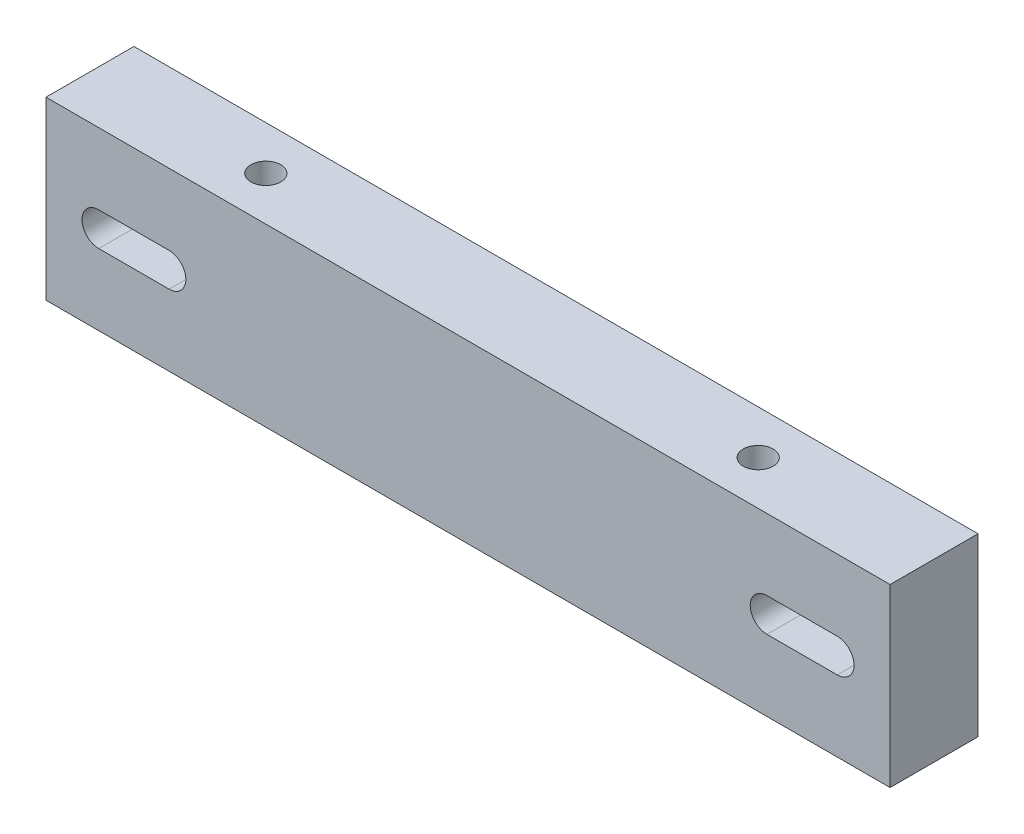
from build123d import *

# Parameters (mm, degrees)
CROQUIS1_W              = 240
CROQUIS1_H              = 25
SALIENTE_EXTRUIR1_DEPTH = 50
CROQUIS2_R              = 4.25
CORTAR_EXTRUIR1_DEPTH   = 25
CORTAR_EXTRUIR3_DEPTH   = 26


with BuildPart() as part:
    # Croquis1 → Saliente-Extruir1 (new body)
    with BuildSketch(Plane(origin=(0, 0, 0), x_dir=(1, 0, 0), z_dir=(0, 1, 0))):
        with Locations((0, 2.5)):
            Rectangle(CROQUIS1_W, CROQUIS1_H)
    extrude(amount=-SALIENTE_EXTRUIR1_DEPTH)

    # Croquis2 → Cortar-Extruir1 (cut)
    with BuildSketch(Plane(origin=(0, 0, 0), x_dir=(1, 0, 0), z_dir=(0, 1, 0))):
        with Locations((-70, 2.5)):
            Circle(CROQUIS2_R)
        with Locations((70, 2.5)):
            Circle(CROQUIS2_R)
    extrude(amount=-CORTAR_EXTRUIR1_DEPTH, mode=Mode.SUBTRACT)

    # Croquis3 → Cortar-Extruir3 (cut, through all)
    with BuildSketch(Plane.XY.offset(10)):
        with BuildLine():
            Line((-105, -20.232520372), (-85, -20.232520372))
            ThreePointArc((-85, -20.232520372), (-80.232520372, -25), (-85, -29.767479628))
            Line((-85, -29.767479628), (-105, -29.767479628))
            ThreePointArc((-105, -29.767479628), (-109.767479628, -25), (-105, -20.232520372))
        make_face()
        with BuildLine():
            Line((85, -20.232520372), (105, -20.232520372))
            ThreePointArc((105, -20.232520372), (109.767479628, -25), (105, -29.767479628))
            Line((105, -29.767479628), (85, -29.767479628))
            ThreePointArc((85, -29.767479628), (80.232520372, -25), (85, -20.232520372))
        make_face()
    extrude(amount=-CORTAR_EXTRUIR3_DEPTH, mode=Mode.SUBTRACT)


solid = part.part
